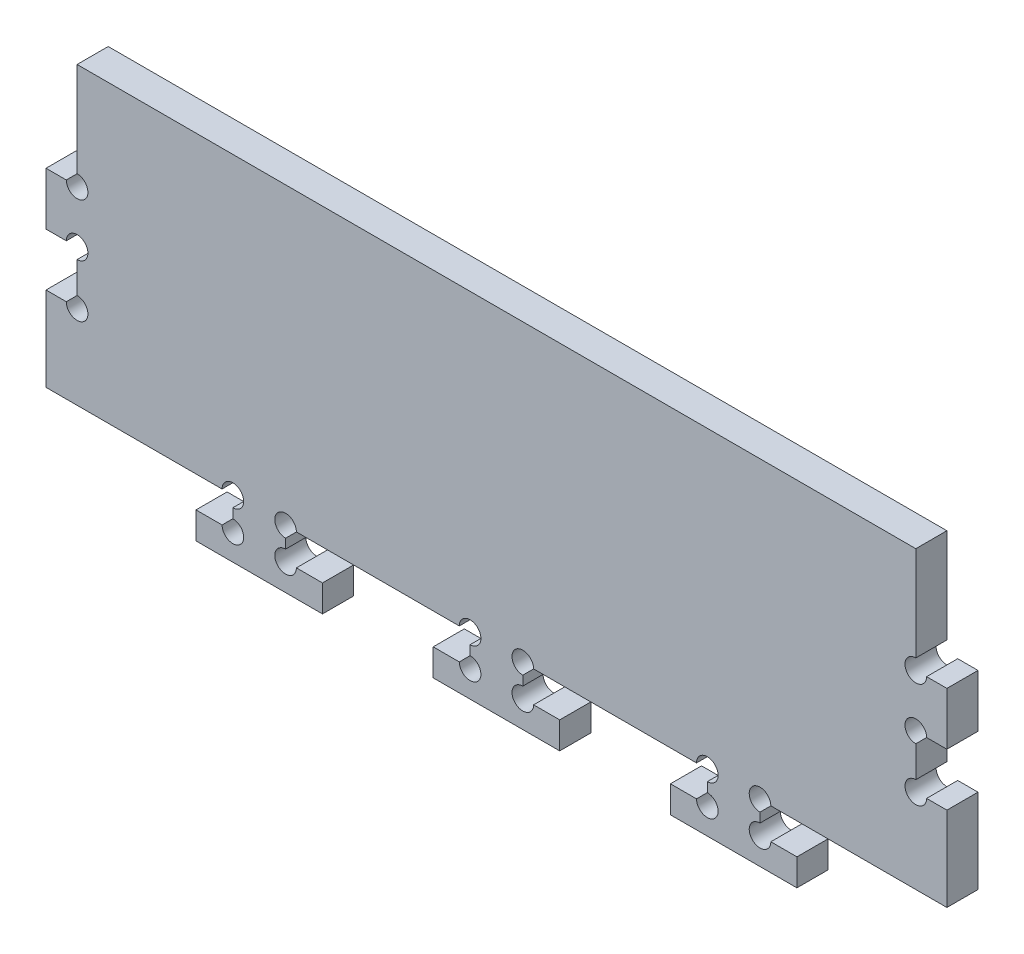
from build123d import *

# Parameters (mm, degrees)
SKETCH1_W           = 170.9
SKETCH1_H           = 70
BOSS_EXTRUDE1_DEPTH = 5.9
CUT_EXTRUDE1_DEPTH  = 6.9
SKETCH3_W           = 5.9
SKETCH3_H           = 10
CUT_EXTRUDE2_DEPTH  = 6.9
SKETCH4_W           = 5.9
SKETCH4_H           = 10
CUT_EXTRUDE3_DEPTH  = 6.9
CUT_EXTRUDE4_REACH  = 7.9
SKETCH5_R           = 2.05


with BuildPart() as part:
    # Sketch1 → Boss-Extrude1 (new body)
    with BuildSketch(Plane.XY):
        Rectangle(SKETCH1_W, SKETCH1_H)
    extrude(amount=BOSS_EXTRUDE1_DEPTH)

    # Sketch2 → Cut-Extrude1 (cut, through all)
    with BuildSketch(Plane.XY.offset(5.9)):
        Polygon((-50, -21), (-85.45, -21), (-85.45, -35), (85.45, -35), (85.45, -21), (50, -21), (50, -26.9), (57, -26.9), (57, -32), (33, -32), (33, -26.9), (40, -26.9), (40, -21), (5, -21), (5, -26.9), (12, -26.9), (12, -32), (-12, -32), (-12, -26.9), (-5, -26.9), (-5, -21), (-40, -21), (-40, -26.9), (-33, -26.9), (-33, -32), (-57, -32), (-57, -26.9), (-50, -26.9), align=None)
    extrude(amount=-CUT_EXTRUDE1_DEPTH, mode=Mode.SUBTRACT)

    # Sketch3 → Cut-Extrude2 (cut, through all)
    with BuildSketch(Plane.XY.offset(5.9)):
        with Locations((82.5, 20)):
            Rectangle(SKETCH3_W, SKETCH3_H)
        with Locations((82.5, 0)):
            Rectangle(SKETCH3_W, SKETCH3_H)
        with Locations((-82.5, 0)):
            Rectangle(SKETCH3_W, SKETCH3_H)
        with Locations((-82.5, 20)):
            Rectangle(SKETCH3_W, SKETCH3_H)
    extrude(amount=-CUT_EXTRUDE2_DEPTH, mode=Mode.SUBTRACT)

    # Sketch4 → Cut-Extrude3 (cut, through all)
    with BuildSketch(Plane.XY.offset(5.9)):
        with Locations((82.5, 30)):
            Rectangle(SKETCH4_W, SKETCH4_H)
        with Locations((-82.5, 30)):
            Rectangle(SKETCH4_W, SKETCH4_H)
    extrude(amount=-CUT_EXTRUDE3_DEPTH, mode=Mode.SUBTRACT)

    # Sketch5 → Cut-Extrude4 (cut, up to next)
    with BuildSketch(Plane.XY.offset(5.9), mode=Mode.PRIVATE) as cut_extrude4_sk1:
        with Locations((-50, -26.9)):
            Circle(SKETCH5_R)
    cut_extrude4_tool1 = extrude(cut_extrude4_sk1.sketch, amount=-CUT_EXTRUDE4_REACH, mode=Mode.PRIVATE) & part.part
    add(cut_extrude4_tool1.solids().sort_by_distance((-50, -26.9, 5.9))[0], mode=Mode.SUBTRACT)
    # Sketch5 → Cut-Extrude4 (cut, up to next)
    with BuildSketch(Plane.XY.offset(5.9), mode=Mode.PRIVATE) as cut_extrude4_sk2:
        with Locations((-40, -26.9)):
            Circle(SKETCH5_R)
    cut_extrude4_tool2 = extrude(cut_extrude4_sk2.sketch, amount=-CUT_EXTRUDE4_REACH, mode=Mode.PRIVATE) & part.part
    add(cut_extrude4_tool2.solids().sort_by_distance((-40, -26.9, 5.9))[0], mode=Mode.SUBTRACT)
    # Sketch5 → Cut-Extrude4 (cut, up to next)
    with BuildSketch(Plane.XY.offset(5.9), mode=Mode.PRIVATE) as cut_extrude4_sk3:
        with Locations((-50, -21)):
            Circle(SKETCH5_R)
    cut_extrude4_tool3 = extrude(cut_extrude4_sk3.sketch, amount=-CUT_EXTRUDE4_REACH, mode=Mode.PRIVATE) & part.part
    add(cut_extrude4_tool3.solids().sort_by_distance((-50, -21, 5.9))[0], mode=Mode.SUBTRACT)
    # Sketch5 → Cut-Extrude4 (cut, up to next)
    with BuildSketch(Plane.XY.offset(5.9), mode=Mode.PRIVATE) as cut_extrude4_sk4:
        with Locations((-40, -21)):
            Circle(SKETCH5_R)
    cut_extrude4_tool4 = extrude(cut_extrude4_sk4.sketch, amount=-CUT_EXTRUDE4_REACH, mode=Mode.PRIVATE) & part.part
    add(cut_extrude4_tool4.solids().sort_by_distance((-40, -21, 5.9))[0], mode=Mode.SUBTRACT)
    # Sketch5 → Cut-Extrude4 (cut, up to next)
    with BuildSketch(Plane.XY.offset(5.9), mode=Mode.PRIVATE) as cut_extrude4_sk5:
        with Locations((-5, -21)):
            Circle(SKETCH5_R)
    cut_extrude4_tool5 = extrude(cut_extrude4_sk5.sketch, amount=-CUT_EXTRUDE4_REACH, mode=Mode.PRIVATE) & part.part
    add(cut_extrude4_tool5.solids().sort_by_distance((-5, -21, 5.9))[0], mode=Mode.SUBTRACT)
    # Sketch5 → Cut-Extrude4 (cut, up to next)
    with BuildSketch(Plane.XY.offset(5.9), mode=Mode.PRIVATE) as cut_extrude4_sk6:
        with Locations((5, -21)):
            Circle(SKETCH5_R)
    cut_extrude4_tool6 = extrude(cut_extrude4_sk6.sketch, amount=-CUT_EXTRUDE4_REACH, mode=Mode.PRIVATE) & part.part
    add(cut_extrude4_tool6.solids().sort_by_distance((5, -21, 5.9))[0], mode=Mode.SUBTRACT)
    # Sketch5 → Cut-Extrude4 (cut, up to next)
    with BuildSketch(Plane.XY.offset(5.9), mode=Mode.PRIVATE) as cut_extrude4_sk7:
        with Locations((-5, -26.9)):
            Circle(SKETCH5_R)
    cut_extrude4_tool7 = extrude(cut_extrude4_sk7.sketch, amount=-CUT_EXTRUDE4_REACH, mode=Mode.PRIVATE) & part.part
    add(cut_extrude4_tool7.solids().sort_by_distance((-5, -26.9, 5.9))[0], mode=Mode.SUBTRACT)
    # Sketch5 → Cut-Extrude4 (cut, up to next)
    with BuildSketch(Plane.XY.offset(5.9), mode=Mode.PRIVATE) as cut_extrude4_sk8:
        with Locations((5, -26.9)):
            Circle(SKETCH5_R)
    cut_extrude4_tool8 = extrude(cut_extrude4_sk8.sketch, amount=-CUT_EXTRUDE4_REACH, mode=Mode.PRIVATE) & part.part
    add(cut_extrude4_tool8.solids().sort_by_distance((5, -26.9, 5.9))[0], mode=Mode.SUBTRACT)
    # Sketch5 → Cut-Extrude4 (cut, up to next)
    with BuildSketch(Plane.XY.offset(5.9), mode=Mode.PRIVATE) as cut_extrude4_sk9:
        with Locations((40, -26.9)):
            Circle(SKETCH5_R)
    cut_extrude4_tool9 = extrude(cut_extrude4_sk9.sketch, amount=-CUT_EXTRUDE4_REACH, mode=Mode.PRIVATE) & part.part
    add(cut_extrude4_tool9.solids().sort_by_distance((40, -26.9, 5.9))[0], mode=Mode.SUBTRACT)
    # Sketch5 → Cut-Extrude4 (cut, up to next)
    with BuildSketch(Plane.XY.offset(5.9), mode=Mode.PRIVATE) as cut_extrude4_sk10:
        with Locations((50, -26.9)):
            Circle(SKETCH5_R)
    cut_extrude4_tool10 = extrude(cut_extrude4_sk10.sketch, amount=-CUT_EXTRUDE4_REACH, mode=Mode.PRIVATE) & part.part
    add(cut_extrude4_tool10.solids().sort_by_distance((50, -26.9, 5.9))[0], mode=Mode.SUBTRACT)
    # Sketch5 → Cut-Extrude4 (cut, up to next)
    with BuildSketch(Plane.XY.offset(5.9), mode=Mode.PRIVATE) as cut_extrude4_sk11:
        with Locations((50, -21)):
            Circle(SKETCH5_R)
    cut_extrude4_tool11 = extrude(cut_extrude4_sk11.sketch, amount=-CUT_EXTRUDE4_REACH, mode=Mode.PRIVATE) & part.part
    add(cut_extrude4_tool11.solids().sort_by_distance((50, -21, 5.9))[0], mode=Mode.SUBTRACT)
    # Sketch5 → Cut-Extrude4 (cut, up to next)
    with BuildSketch(Plane.XY.offset(5.9), mode=Mode.PRIVATE) as cut_extrude4_sk12:
        with Locations((40, -21)):
            Circle(SKETCH5_R)
    cut_extrude4_tool12 = extrude(cut_extrude4_sk12.sketch, amount=-CUT_EXTRUDE4_REACH, mode=Mode.PRIVATE) & part.part
    add(cut_extrude4_tool12.solids().sort_by_distance((40, -21, 5.9))[0], mode=Mode.SUBTRACT)
    # Sketch5 → Cut-Extrude4 (cut, up to next)
    with BuildSketch(Plane.XY.offset(5.9), mode=Mode.PRIVATE) as cut_extrude4_sk13:
        with Locations((79.55, -5)):
            Circle(SKETCH5_R)
    cut_extrude4_tool13 = extrude(cut_extrude4_sk13.sketch, amount=-CUT_EXTRUDE4_REACH, mode=Mode.PRIVATE) & part.part
    add(cut_extrude4_tool13.solids().sort_by_distance((79.55, -5, 5.9))[0], mode=Mode.SUBTRACT)
    # Sketch5 → Cut-Extrude4 (cut, up to next)
    with BuildSketch(Plane.XY.offset(5.9), mode=Mode.PRIVATE) as cut_extrude4_sk14:
        with Locations((79.55, 5)):
            Circle(SKETCH5_R)
    cut_extrude4_tool14 = extrude(cut_extrude4_sk14.sketch, amount=-CUT_EXTRUDE4_REACH, mode=Mode.PRIVATE) & part.part
    add(cut_extrude4_tool14.solids().sort_by_distance((79.55, 5, 5.9))[0], mode=Mode.SUBTRACT)
    # Sketch5 → Cut-Extrude4 (cut, up to next)
    with BuildSketch(Plane.XY.offset(5.9), mode=Mode.PRIVATE) as cut_extrude4_sk15:
        with Locations((79.55, 15)):
            Circle(SKETCH5_R)
    cut_extrude4_tool15 = extrude(cut_extrude4_sk15.sketch, amount=-CUT_EXTRUDE4_REACH, mode=Mode.PRIVATE) & part.part
    add(cut_extrude4_tool15.solids().sort_by_distance((79.55, 15, 5.9))[0], mode=Mode.SUBTRACT)
    # Sketch5 → Cut-Extrude4 (cut, up to next)
    with BuildSketch(Plane.XY.offset(5.9), mode=Mode.PRIVATE) as cut_extrude4_sk16:
        with Locations((-79.55, 15)):
            Circle(SKETCH5_R)
    cut_extrude4_tool16 = extrude(cut_extrude4_sk16.sketch, amount=-CUT_EXTRUDE4_REACH, mode=Mode.PRIVATE) & part.part
    add(cut_extrude4_tool16.solids().sort_by_distance((-79.55, 15, 5.9))[0], mode=Mode.SUBTRACT)
    # Sketch5 → Cut-Extrude4 (cut, up to next)
    with BuildSketch(Plane.XY.offset(5.9), mode=Mode.PRIVATE) as cut_extrude4_sk17:
        with Locations((-79.55, 5)):
            Circle(SKETCH5_R)
    cut_extrude4_tool17 = extrude(cut_extrude4_sk17.sketch, amount=-CUT_EXTRUDE4_REACH, mode=Mode.PRIVATE) & part.part
    add(cut_extrude4_tool17.solids().sort_by_distance((-79.55, 5, 5.9))[0], mode=Mode.SUBTRACT)
    # Sketch5 → Cut-Extrude4 (cut, up to next)
    with BuildSketch(Plane.XY.offset(5.9), mode=Mode.PRIVATE) as cut_extrude4_sk18:
        with Locations((-79.55, -5)):
            Circle(SKETCH5_R)
    cut_extrude4_tool18 = extrude(cut_extrude4_sk18.sketch, amount=-CUT_EXTRUDE4_REACH, mode=Mode.PRIVATE) & part.part
    add(cut_extrude4_tool18.solids().sort_by_distance((-79.55, -5, 5.9))[0], mode=Mode.SUBTRACT)


solid = part.part
